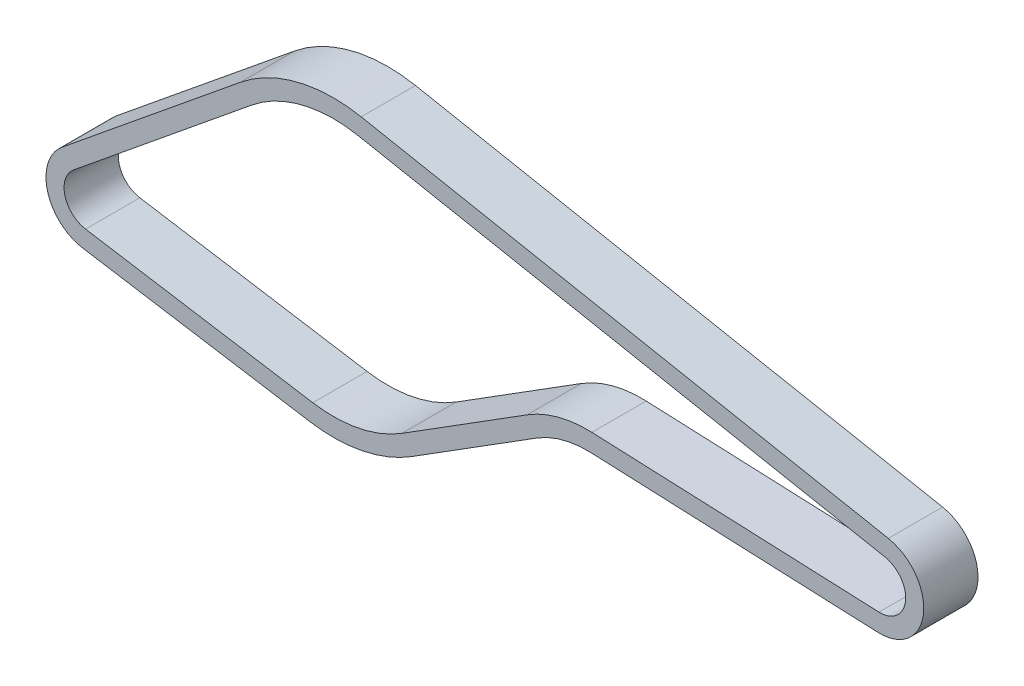
from build123d import *

# Parameters (mm, degrees)
RESSALTO_EXTRUS_O1_DEPTH = 4.5


with BuildPart() as part:
    # Esboço1 → Ressalto-extrusão1 (new body, symmetric)
    with BuildSketch(Plane.XY):
        with BuildLine():
            ThreePointArc((90.369647409, -7.243523717), (97.877064824, -0.841102514), (92.047248027, 7.119145574))
            Line((92.047248027, 7.119145574), (4.614891567, 23.959607172))
            ThreePointArc((4.614891567, 23.959607172), (-5.96196459, 23.660409511), (-15.417653704, 18.911794052))
            Line((-15.417653704, 18.911794052), (-45.010991752, -5.213883118))
            ThreePointArc((-45.010991752, -5.213883118), (-47.432888855, -12.709604263), (-41.587603866, -17.990140644))
            Line((-41.587603866, -17.990140644), (-3.896182749, -24.086920932))
            ThreePointArc((-3.896182749, -24.086920932), (4.853764128, -23.912360272), (12.979282584, -20.661515521))
            Line((12.979282584, -20.661515521), (33.738260666, -7.621008284))
            ThreePointArc((33.738260666, -7.621008284), (38.064016153, -5.740396954), (42.753139424, -5.229532527))
            Line((42.753139424, -5.229532527), (90.369647409, -7.243523717))
        make_face()
        with BuildLine():
            ThreePointArc((-13.522040544, 16.586573471), (-5.228936157, 20.751342768), (4.047486866, 21.013753831))
            Line((4.047486866, 21.013753831), (91.479843326, 4.173292233))
            ThreePointArc((91.479843326, 4.173292233), (94.897322138, -0.493060095), (90.496422274, -4.246203558))
            Line((90.496422274, -4.246203558), (42.87991429, -2.232212369))
            ThreePointArc((42.87991429, -2.232212369), (37.294780203, -2.840694201), (32.142447233, -5.080658015))
            Line((32.142447233, -5.080658015), (11.383469151, -18.121165252))
            ThreePointArc((11.383469151, -18.121165252), (4.25698985, -20.972315976), (-3.417143886, -21.12541426))
            Line((-3.417143886, -21.12541426), (-41.108565003, -15.028633972))
            ThreePointArc((-41.108565003, -15.028633972), (-44.535111376, -11.933147128), (-43.115378592, -7.539103698))
            Line((-43.115378592, -7.539103698), (-13.522040544, 16.586573471))
        make_face(mode=Mode.SUBTRACT)
    extrude(amount=RESSALTO_EXTRUS_O1_DEPTH, both=True)


solid = part.part
